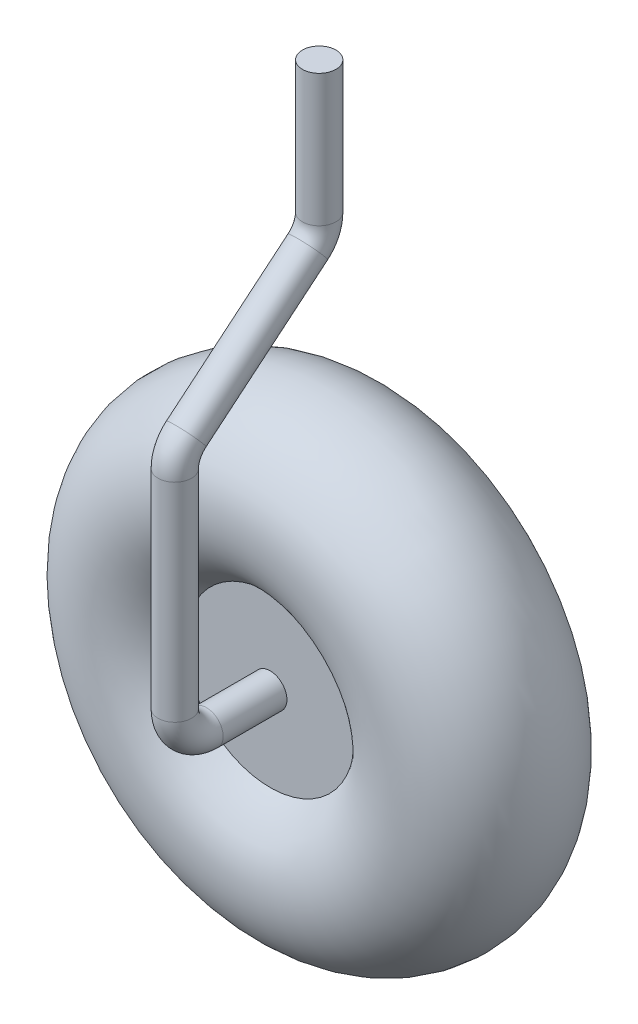
from build123d import *

# Parameters (mm, degrees)
SKETCH1_ONE_SIDE_W = 7.87092143
SKETCH1_ONE_SIDE_H = 6.774542772
SKETCH1_ONE_SIDE_R = 6.768574812
SKETCH3_R          = 1.344240024


with BuildPart() as part:
    # Sketch1 one side → Revolve1 (revolve)
    with BuildSketch(Plane(origin=(0, 0, 0), x_dir=(0, 0, -1), z_dir=(1, 0, 0)), mode=Mode.PRIVATE) as revolve1_sk:
        with Locations((0, -3.387271386)):
            Rectangle(SKETCH1_ONE_SIDE_W, SKETCH1_ONE_SIDE_H)
        with Locations((0, 12.281425188)):
            Circle(SKETCH1_ONE_SIDE_R)
    revolve(revolve1_sk.sketch.rotate(Axis((0, 0, 0), (0, 0, 1)), 270), axis=Axis((0, 0, 0), (0, 0, 1)))

    # Sweep1: sweep along a path in Sketch2
    with BuildLine(Plane(origin=(0, 0, 0), x_dir=(0, 0, -1), z_dir=(1, 0, 0))) as sweep1_path:
        Line((0, 0), (-9.050514624, 0))
        ThreePointArc((-9.050514624, 0), (-10.846565848, 0.743948776), (-11.590514624, 2.54))
        Line((-11.590514624, 2.54), (-11.590514624, 19.227855259))
        ThreePointArc((-11.590514624, 19.227855259), (-11.350486879, 20.305689952), (-10.675768463, 21.179815801))
        Line((-10.675768463, 21.179815801), (-0.914746161, 29.307100461))
        ThreePointArc((-0.914746161, 29.307100461), (-0.240027745, 30.181226311), (0, 31.259061004))
        Line((0, 31.259061004), (0, 41.860852469))
    # Sketch3 → Sweep1 (sweep)
    with BuildSketch(Plane.XY.offset(3.935460715)):
        Circle(SKETCH3_R)
    sweep(path=sweep1_path.line)


solid = part.part
